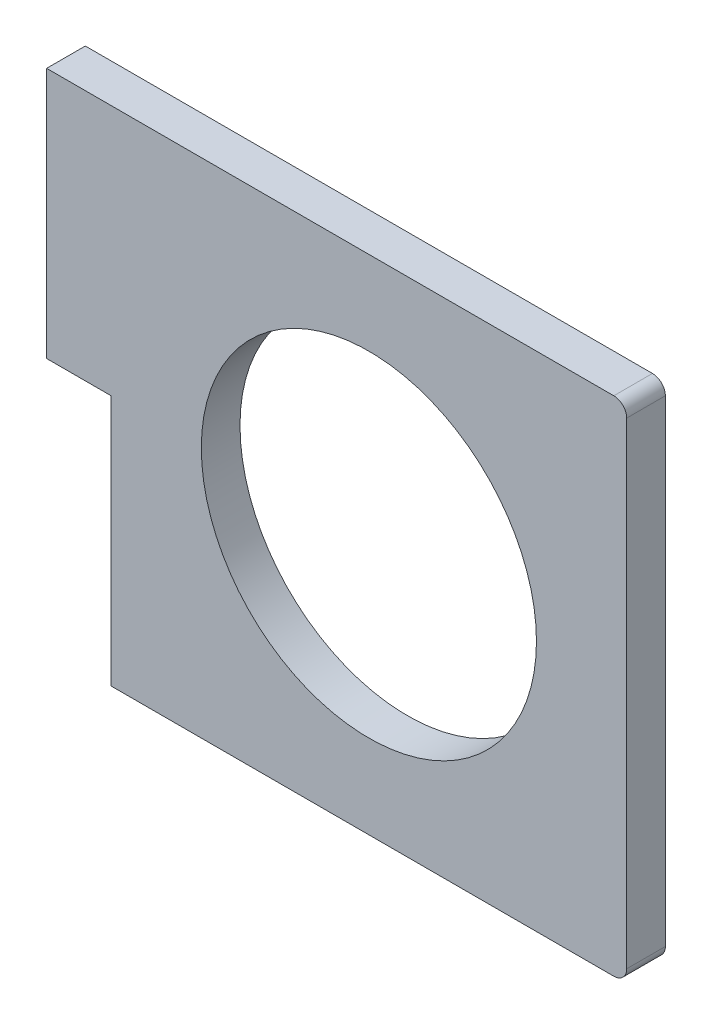
from build123d import *

# Parameters (mm, degrees)
SKETCH1_R           = 26
BOSS_EXTRUDE1_DEPTH = 6
FILLET1_R           = 2


with BuildPart() as part:
    # Sketch1 → Boss-Extrude1 (new body)
    with BuildSketch(Plane.XY):
        Polygon((0, 0), (80, 0), (80, 78), (0, 78), (-10, 78), (-10, 39), (0, 39), align=None)
        with Locations((40, 39)):
            Circle(SKETCH1_R, mode=Mode.SUBTRACT)
    extrude(amount=BOSS_EXTRUDE1_DEPTH)

    # Fillet1
    fillet1_edges = [part.edges().sort_by_distance(p)[0] for p in [
        (80, 78, 3),
        (80, 0, 3),
    ]]
    fillet(fillet1_edges, radius=FILLET1_R)


solid = part.part
